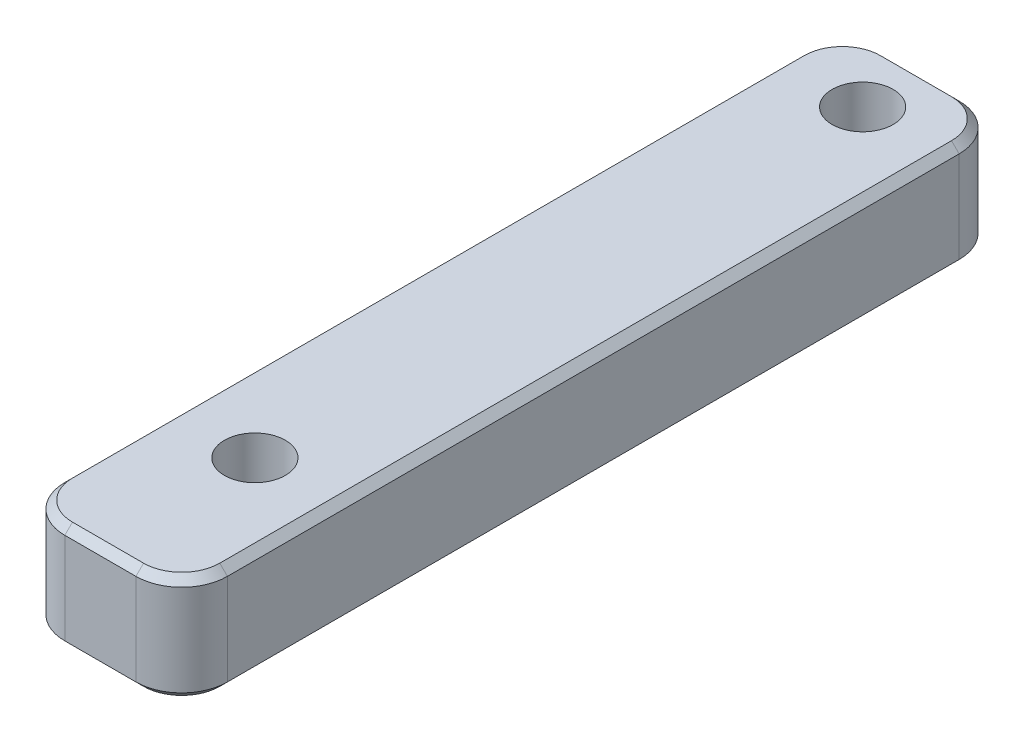
from build123d import *

# Parameters (mm, degrees)
SKETCH_1_W          = 5.332575
SKETCH_1_H          = 27
EXTRUDE_1_DEPTH     = 3.5
FILLET_1_R          = 1.5
SKETCH_2_R          = 1
CUT_EXTRUDE_1_DEPTH = 4.5
CHAMFER_1_SIZE      = 0.25


with BuildPart() as part:
    # ｽｹｯﾁ1 → ﾎﾞｽ - 押し出し1 (new body)
    with BuildSketch(Plane(origin=(0, 0, 0), x_dir=(1, 0, 0), z_dir=(0, 1, 0))):
        with Locations((2.6662875, 13.5)):
            Rectangle(SKETCH_1_W, SKETCH_1_H)
    extrude(amount=EXTRUDE_1_DEPTH)

    # ﾌｨﾚｯﾄ1
    fillet_1_edges = [part.edges().sort_by_distance(p)[0] for p in [
        (5.332575, 1.75, -27),
        (5.332575, 1.75, 0),
        (0, 1.75, 0),
        (0, 1.75, -27),
    ]]
    fillet(fillet_1_edges, radius=FILLET_1_R)

    # ｽｹｯﾁ2 → ｶｯﾄ - 押し出し1 (cut, through all)
    with BuildSketch(Plane(origin=(0, 3.5, 0), x_dir=(1, 0, 0), z_dir=(0, 1, 0))):
        with Locations((2.6662875, 25)):
            Circle(SKETCH_2_R)
        with Locations((2.6662875, 5.06736)):
            Circle(SKETCH_2_R)
    extrude(amount=-CUT_EXTRUDE_1_DEPTH, mode=Mode.SUBTRACT)

    # 面取り1
    chamfer_1_edges = [part.edges().sort_by_distance(p)[0] for p in [
        (5.332575, 0, -13.5),
        (5.332575, 3.5, -13.5),
        (2.6662875, 0, -27),
        (2.6662875, 0, 0),
        (0, 0, -13.5),
        (4.893235172, 0, -26.560660172),
        (0.439339828, 0, -26.560660172),
        (0.439339828, 0, -0.439339828),
        (4.893235172, 0, -0.439339828),
        (2.6662875, 3.5, 0),
        (2.6662875, 3.5, -27),
        (0, 3.5, -13.5),
        (4.893235172, 3.5, -26.560660172),
        (0.439339828, 3.5, -26.560660172),
        (0.439339828, 3.5, -0.439339828),
        (4.893235172, 3.5, -0.439339828),
    ]]
    chamfer(chamfer_1_edges, length=CHAMFER_1_SIZE)


solid = part.part
